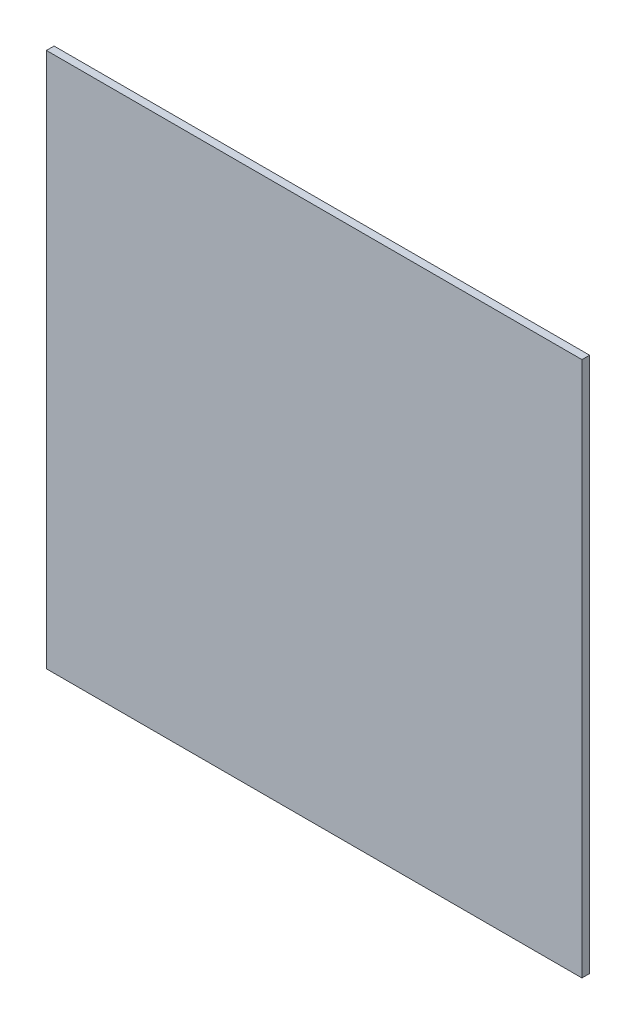
from build123d import *

# Parameters (mm, degrees)
CROQUIS1_W              = 70
CROQUIS1_H              = 70
SALIENTE_EXTRUIR1_DEPTH = 1


with BuildPart() as part:
    # Croquis1 → Saliente-Extruir1 (new body)
    with BuildSketch(Plane.XY):
        with Locations((-27.444130776, -10.515021459)):
            Rectangle(CROQUIS1_W, CROQUIS1_H)
    extrude(amount=SALIENTE_EXTRUIR1_DEPTH)


solid = part.part
